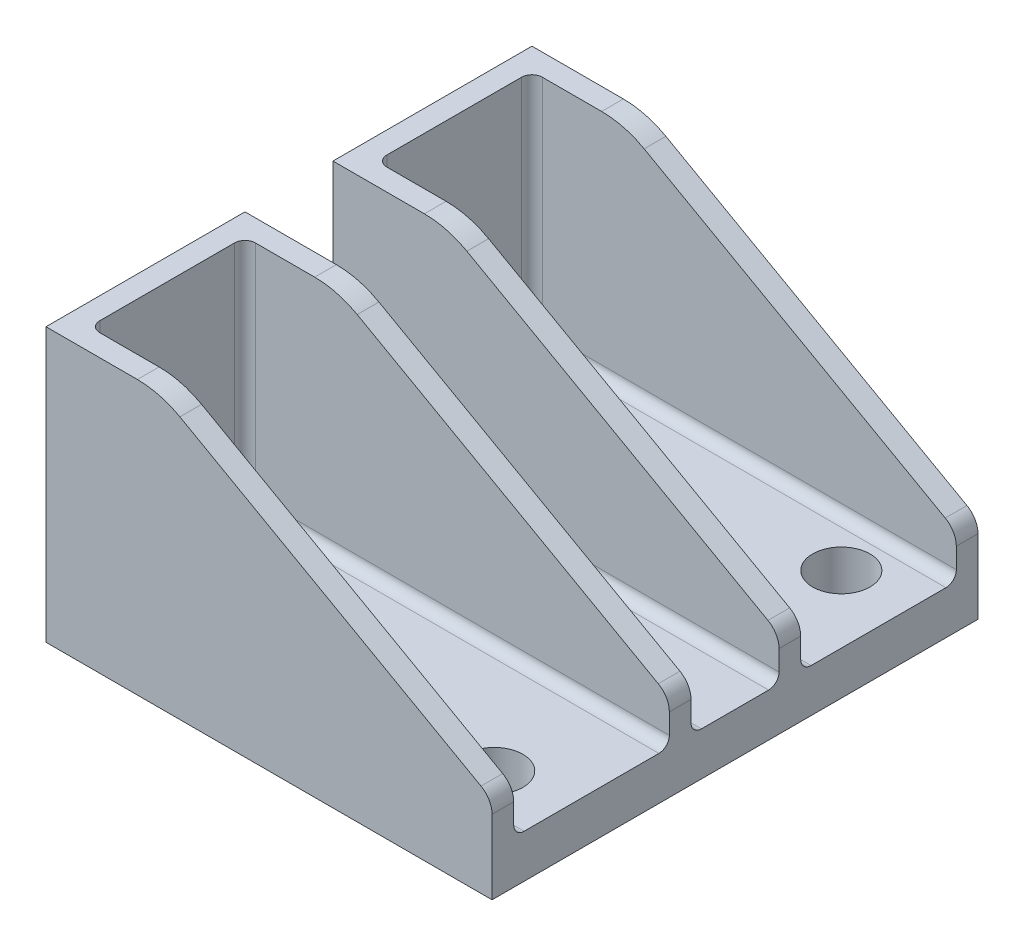
from build123d import *

# Parameters (mm, degrees)
SKETCH1_W            = 32.64025
SKETCH1_H            = 35.56
SKETCH1_R            = 2.1
BOSS_EXTRUDE2_DEPTH  = 3.175
BOSS_EXTRUDE3_DEPTH  = 1.5875
SKETCH4_W            = 11.385
SKETCH4_H            = 16.825
SKETCH4_R            = 2.45
BOSS_EXTRUDE4_DEPTH  = 1.5875
MIRROR2_COPY_1_DEPTH = 1.5875
FILLET1_R            = 0.762
FILLET2_R            = 0.762
FILLET6_R            = 0.762
FILLET7_R            = 0.762


with BuildPart() as part:
    # Sketch1 → Boss-Extrude2 (new body)
    with BuildSketch(Plane(origin=(0, 0, 0), x_dir=(1, 0, 0), z_dir=(0, 1, 0))):
        with Locations((24.319875, 0)):
            Rectangle(SKETCH1_W, SKETCH1_H)
        with Locations((35.71875, 12.7)):
            Circle(SKETCH1_R, mode=Mode.SUBTRACT)
        with Locations((35.71875, -12.7)):
            Circle(SKETCH1_R, mode=Mode.SUBTRACT)
    extrude(amount=BOSS_EXTRUDE2_DEPTH)

    # Sketch2 → Boss-Extrude3 (add)
    with BuildSketch(Plane.XY.offset(17.78)):
        with BuildLine():
            Line((17.798889871, 19.185782349), (39.830221584, 6.805062799))
            ThreePointArc((39.830221584, 6.805062799), (40.422680511, 6.222841365), (40.64, 5.421117212))
            Line((40.64, 5.421117212), (40.64, 3.175))
            Line((40.64, 3.175), (7.99975, 3.175))
            Line((7.99975, 3.175), (7.99975, 20))
            Line((7.99975, 20), (11.5875, 20))
            Line((11.5875, 20), (14.688003537, 20))
            ThreePointArc((14.688003537, 20), (16.295840918, 19.793074064), (17.798889871, 19.185782349))
        make_face()
    boss_extrude3 = extrude(amount=-BOSS_EXTRUDE3_DEPTH)

    # Mirror1: Boss-Extrude3 across plane
    add(boss_extrude3.mirror(Plane.XY.offset(10.5)))

    # Sketch4 → Boss-Extrude4 (add)
    with BuildSketch(Plane.ZY.offset(-7.99975)):
        with Locations((10.5, 11.5875)):
            Rectangle(SKETCH4_W, SKETCH4_H)
        with Locations((10.5, 10)):
            Circle(SKETCH4_R, mode=Mode.SUBTRACT)
    boss_extrude4 = extrude(amount=-BOSS_EXTRUDE4_DEPTH)

    # Mirror2: Boss-Extrude3, Boss-Extrude4 across plane
    add(boss_extrude3.mirror(Plane.XY))
    add(boss_extrude4.mirror(Plane.XY))

    # Mirror2 copy 1 sketch → Mirror2 copy 1 (add)
    with BuildSketch(Plane.XY.offset(-3.22)):
        with BuildLine():
            Line((17.798889871, 19.185782349), (39.830221584, 6.805062799))
            ThreePointArc((39.830221584, 6.805062799), (40.422680511, 6.222841365), (40.64, 5.421117212))
            Line((40.64, 5.421117212), (40.64, 3.175))
            Line((40.64, 3.175), (7.99975, 3.175))
            Line((7.99975, 3.175), (7.99975, 20))
            Line((7.99975, 20), (11.5875, 20))
            Line((11.5875, 20), (14.688003537, 20))
            ThreePointArc((14.688003537, 20), (16.295840918, 19.793074064), (17.798889871, 19.185782349))
        make_face()
    extrude(amount=-MIRROR2_COPY_1_DEPTH)

    # Fillet1
    fillet1_edges = [part.edges().sort_by_distance(p)[0] for p in [
        (9.58725, 11.5875, 4.8075),
    ]]
    fillet(fillet1_edges, radius=FILLET1_R)

    # Fillet2
    fillet2_edges = [part.edges().sort_by_distance(p)[0] for p in [
        (9.58725, 11.5875, 16.1925),
    ]]
    fillet(fillet2_edges, radius=FILLET2_R)

    # Fillet6
    fillet6_edges = [part.edges().sort_by_distance(p)[0] for p in [
        (24.319875, 3.175, 3.22),
    ]]
    fillet(fillet6_edges, radius=FILLET6_R)

    # Fillet7
    fillet7_edges = [part.edges().sort_by_distance(p)[0] for p in [
        (24.319875, 3.175, -3.22),
        (25.113625, 3.175, -4.8075),
        (25.113625, 3.175, -16.1925),
        (9.58725, 11.5875, -16.1925),
        (9.58725, 11.5875, -4.8075),
        (9.58725, 3.175, -10.5),
        (25.494625, 3.175, 4.8075),
        (9.58725, 3.175, 10.5),
        (9.810434633, 3.175, 5.030684633),
        (25.494625, 3.175, 16.1925),
        (9.810434633, 3.175, 15.969315367),
    ]]
    fillet(fillet7_edges, radius=FILLET7_R)


solid = part.part
